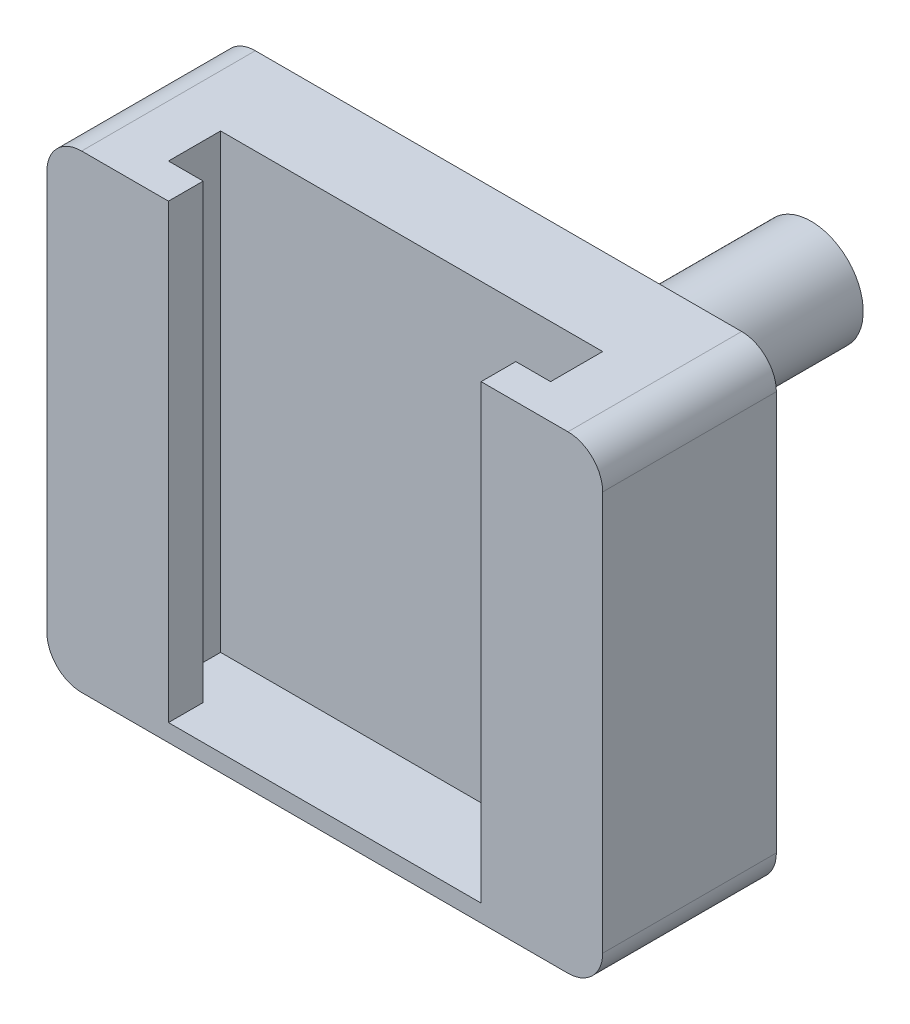
from build123d import *

# Parameters (mm, degrees)
SKETCH1_W           = 32
SKETCH1_H           = 27
BOSS_EXTRUDE1_DEPTH = 10
FILLET1_R           = 2
CUT_EXTRUDE4_DEPTH  = 26
SKETCH4_R           = 3
BOSS_EXTRUDE2_DEPTH = 18
FILLET2_R           = 2


with BuildPart() as part:
    # Sketch1 → Boss-Extrude1 (new body)
    with BuildSketch(Plane.XY):
        Rectangle(SKETCH1_W, SKETCH1_H)
    extrude(amount=BOSS_EXTRUDE1_DEPTH)

    # Fillet1
    fillet1_edges = [part.edges().sort_by_distance(p)[0] for p in [
        (-16, -13.5, 5),
        (16, -13.5, 5),
        (16, 13.5, 5),
        (-16, 13.5, 5),
    ]]
    fillet(fillet1_edges, radius=FILLET1_R)

    # Sketch2 → Cut-Extrude4 (cut)
    with BuildSketch(Plane(origin=(0, 13.5, 0), x_dir=(1, 0, 0), z_dir=(0, 1, 0))):
        Polygon((-9, -10), (-9, -8), (-11, -8), (-11, -5), (11, -5), (11, -8), (9, -8), (9, -10), align=None)
    extrude(amount=-CUT_EXTRUDE4_DEPTH, mode=Mode.SUBTRACT)

    # Sketch4 → Boss-Extrude2 (add)
    with BuildSketch(Plane(origin=(0, 0, 0), x_dir=(-1, 0, 0), z_dir=(0, 0, -1))):
        Circle(SKETCH4_R)
    extrude(amount=BOSS_EXTRUDE2_DEPTH)

    # Fillet2
    fillet2_edges = [part.edges().sort_by_distance(p)[0] for p in [
        (3, 0, 0),
    ]]
    fillet(fillet2_edges, radius=FILLET2_R)


solid = part.part
